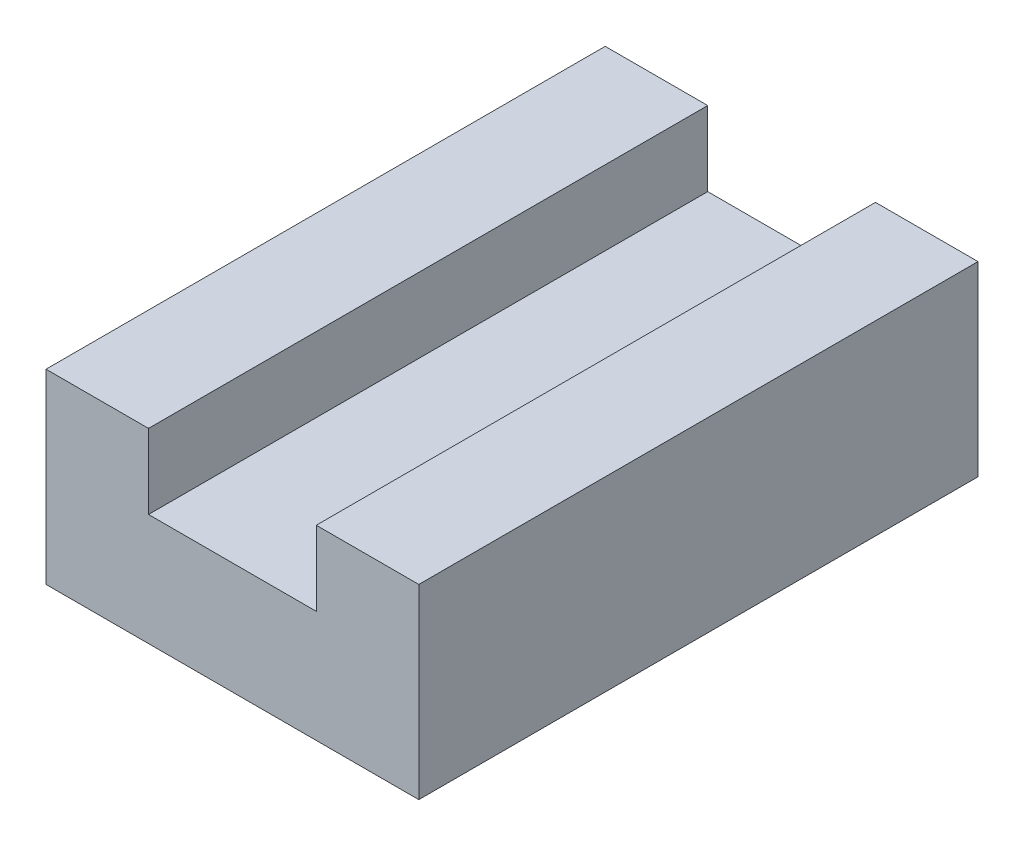
from build123d import *

# Parameters (mm, degrees)
SKETCH1_W           = 20
SKETCH1_H           = 30
BOSS_EXTRUDE1_DEPTH = 10
SKETCH2_W           = 9
SKETCH2_H           = 4
CUT_EXTRUDE1_DEPTH  = 31
SKETCH3_R           = 1.5
CUT_EXTRUDE2_DEPTH  = 5


with BuildPart() as part:
    # Sketch1 → Boss-Extrude1 (new body)
    with BuildSketch(Plane(origin=(0, 0, 0), x_dir=(1, 0, 0), z_dir=(0, 1, 0))):
        with Locations((10, 15)):
            Rectangle(SKETCH1_W, SKETCH1_H)
    extrude(amount=BOSS_EXTRUDE1_DEPTH)

    # Sketch2 → Cut-Extrude1 (cut, through all)
    with BuildSketch(Plane.XY):
        with Locations((10, 8)):
            Rectangle(SKETCH2_W, SKETCH2_H)
    extrude(amount=-CUT_EXTRUDE1_DEPTH, mode=Mode.SUBTRACT)

    # Sketch3 → Cut-Extrude2 (cut)
    with BuildSketch(Plane.XZ):
        with Locations((2.5, -19.682120583)):
            Circle(SKETCH3_R)
        with Locations((17.5, -19.682120583)):
            Circle(SKETCH3_R)
        with Locations((17.5, -9.682120583)):
            Circle(SKETCH3_R)
        with Locations((2.5, -9.682120583)):
            Circle(SKETCH3_R)
    extrude(amount=-CUT_EXTRUDE2_DEPTH, mode=Mode.SUBTRACT)


solid = part.part
